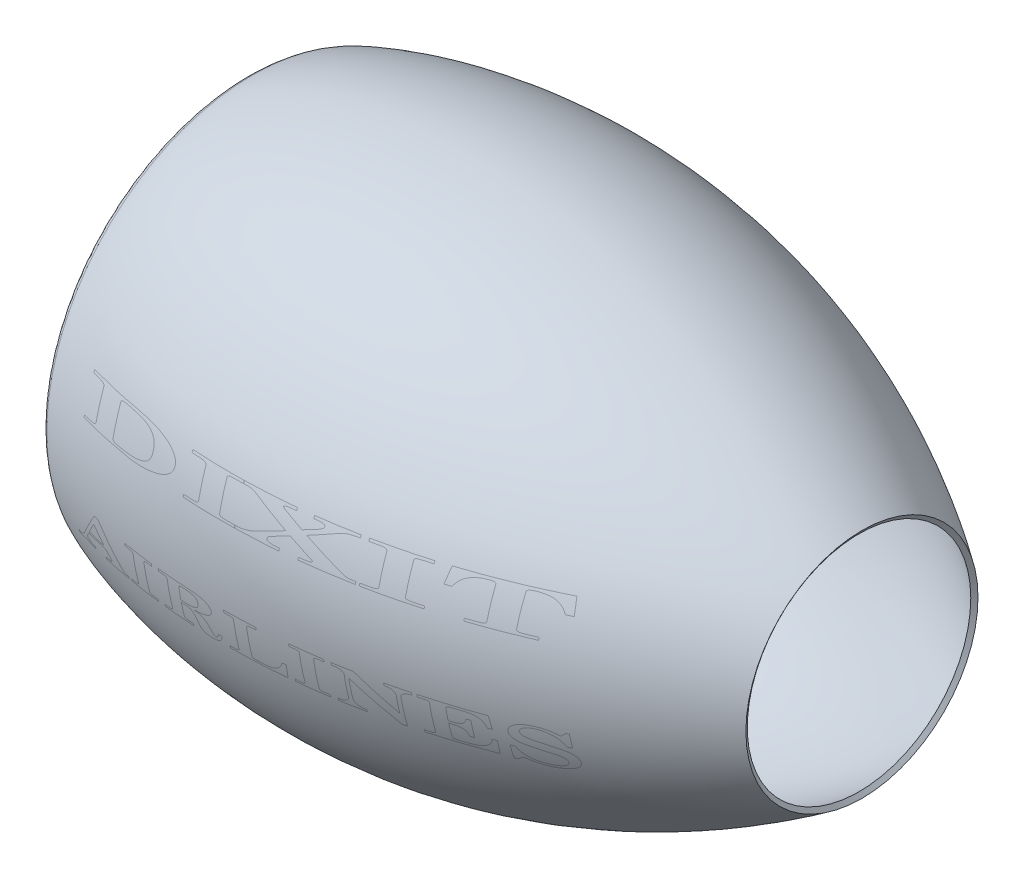
from build123d import *

# Parameters (mm, degrees)
THICKEN1_T1 = 5


with BuildPart() as body_1:
    # Surface-Revolve1: a surface, the sketch's curves turned about an axis
    with BuildLine(Plane.XY, mode=Mode.PRIVATE) as surface_revolve1_1_path:
        Line((64.124419527, 190), (39.124419527, 190))
        Line((39.124419527, 190), (25, 180))
        Line((25, 180), (0, 180))
        add(Edge.make_bspline(
            [(0, 180), (-7.31761437, 184.716451762), (-7.31761437, 189.521594581), (0, 194.415428455)],
            knots=[0, 0, 0, 0, 1, 1, 1, 1], degree=3))
        add(Edge.make_bspline(
            [(0, 194.415428455), (11.83537059, 202.330622476), (280.589620529, 311.261194418), (580, 107.495987807)],
            knots=[0, 0, 0, 0, 1, 1, 1, 1], degree=3))
    surface_revolve1_1 = Shell.revolve(surface_revolve1_1_path.wire(), 360, Axis((-307.32177264, 0, 0), (1, 0, 0)))
    add(Solid.thicken(surface_revolve1_1, THICKEN1_T1))


solid = body_1.part
